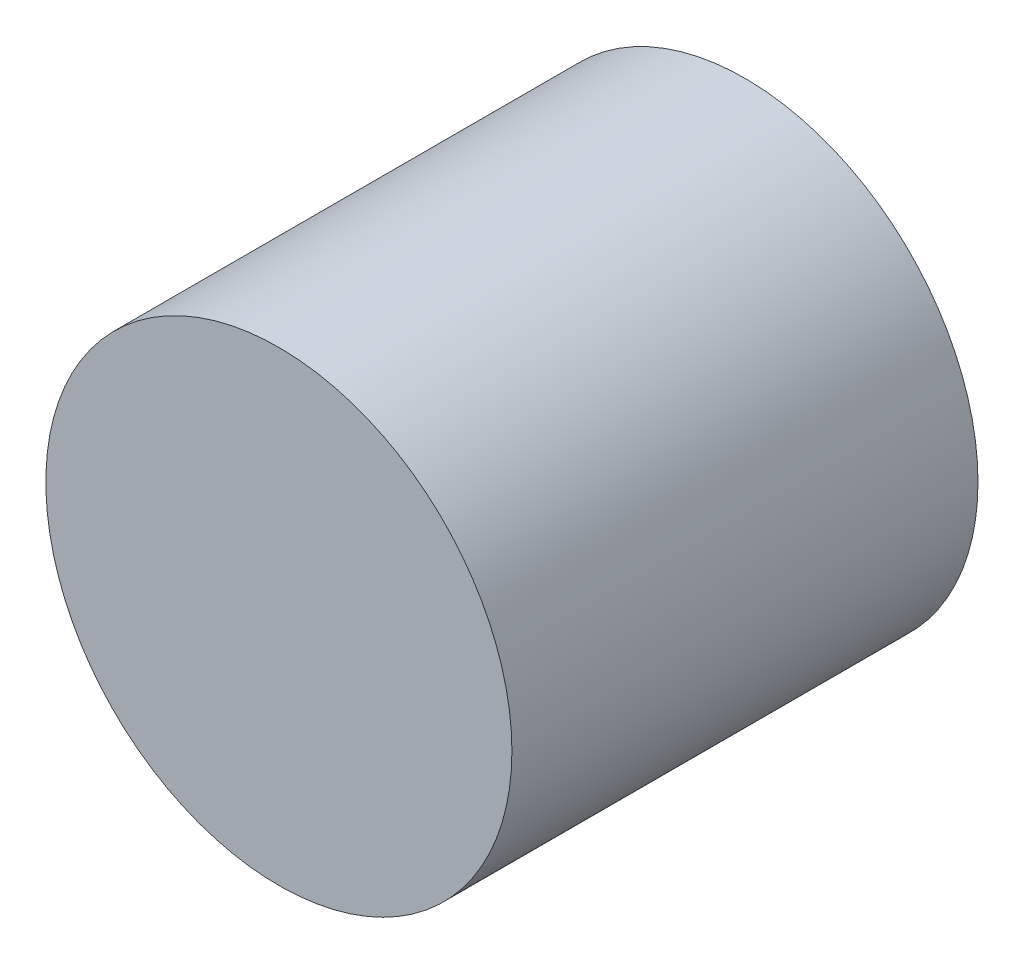
from build123d import *

# Parameters (mm, degrees)
SKETCH_1_R      = 5
EXTRUDE_1_DEPTH = 10


with BuildPart() as part:
    # 草图1 → 凸台-拉伸1 (new body)
    with BuildSketch(Plane.XY):
        with Locations((137.489166817, 29.365546519)):
            Circle(SKETCH_1_R)
    extrude(amount=EXTRUDE_1_DEPTH)


solid = part.part
